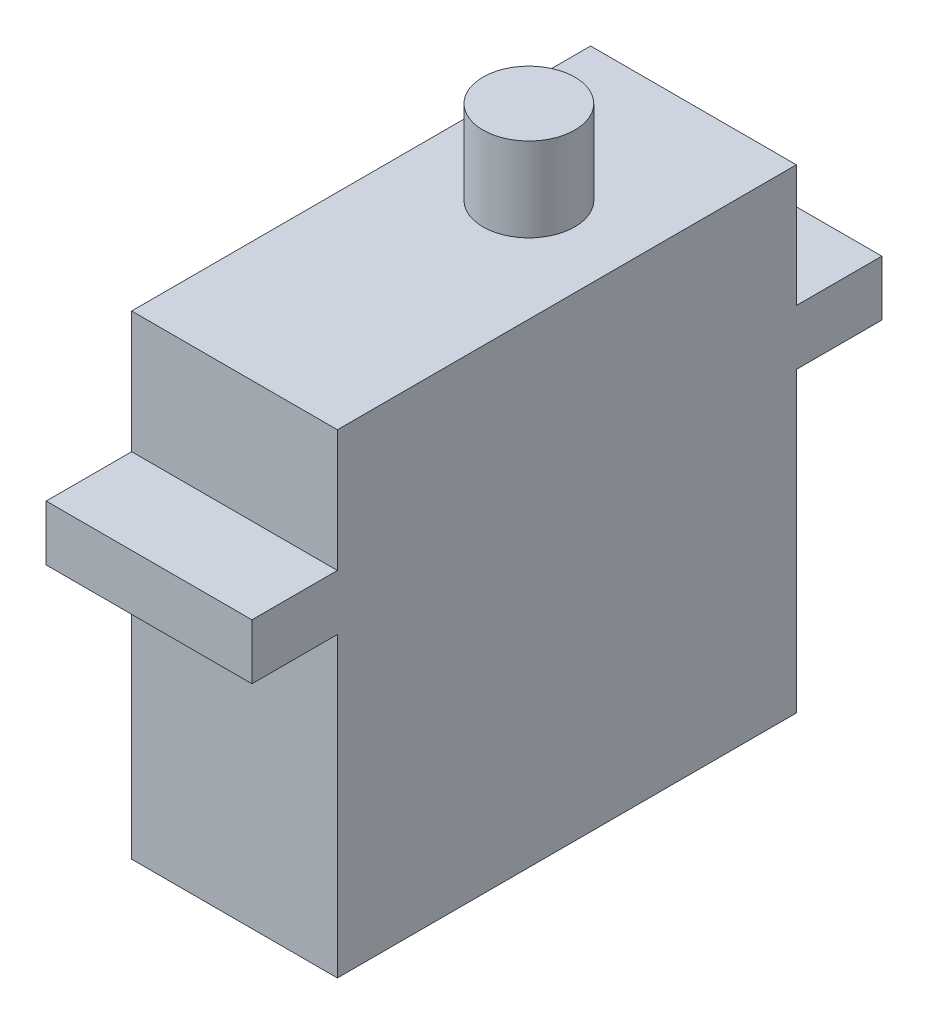
from build123d import *

# Parameters (mm, degrees)
SKETCH2_W           = 29
SKETCH2_H           = 30
SKETCH2_W_2         = 5.4
SKETCH2_H_2         = 3.5
SKETCH2_W_3         = 5.8
SKETCH2_H_3         = 5.3
BOSS_EXTRUDE1_DEPTH = 13
CUT_EXTRUDE1_DEPTH  = 5.3


with BuildPart() as part:
    # Sketch2 → Boss-Extrude1 (new body)
    with BuildSketch(Plane(origin=(0, 0, 0), x_dir=(0, 0, -1), z_dir=(1, 0, 0))):
        Rectangle(SKETCH2_W, SKETCH2_H)
        with Locations((-17.2, 5.55)):
            Rectangle(SKETCH2_W_2, SKETCH2_H_2)
        with Locations((4.1, 17.65)):
            Rectangle(SKETCH2_W_3, SKETCH2_H_3)
        with Locations((17.2, 5.55)):
            Rectangle(SKETCH2_W_2, SKETCH2_H_2)
    extrude(amount=BOSS_EXTRUDE1_DEPTH)

    # Sketch3 → Cut-Extrude1 (cut)
    with BuildSketch(Plane(origin=(0, 15, 0), x_dir=(1, 0, 0), z_dir=(0, 1, 0))):
        with BuildLine():
            Line((6.5, 1.2), (9.4, 1.2))
            Line((9.4, 1.2), (9.4, 4.1))
            ThreePointArc((9.4, 4.1), (8.550609665, 2.049390335), (6.5, 1.2))
        make_face()
        with BuildLine():
            ThreePointArc((6.5, 7), (8.550609665, 6.150609665), (9.4, 4.1))
            Line((9.4, 4.1), (9.4, 7))
            Line((9.4, 7), (6.5, 7))
        make_face()
        with BuildLine():
            ThreePointArc((3.6, 4.1), (4.449390335, 6.150609665), (6.5, 7))
            Line((6.5, 7), (3.6, 7))
            Line((3.6, 7), (3.6, 4.1))
        make_face()
        with BuildLine():
            Line((3.6, 1.2), (6.5, 1.2))
            ThreePointArc((6.5, 1.2), (4.449390335, 2.049390335), (3.6, 4.1))
            Line((3.6, 4.1), (3.6, 1.2))
        make_face()
        Polygon((0, 1.2), (3.6, 1.2), (3.6, 4.1), (3.6, 7), (0, 7), align=None)
        Polygon((9.4, 1.2), (13, 1.2), (13, 7), (9.4, 7), (9.4, 4.1), align=None)
    extrude(amount=CUT_EXTRUDE1_DEPTH, mode=Mode.SUBTRACT)


solid = part.part
